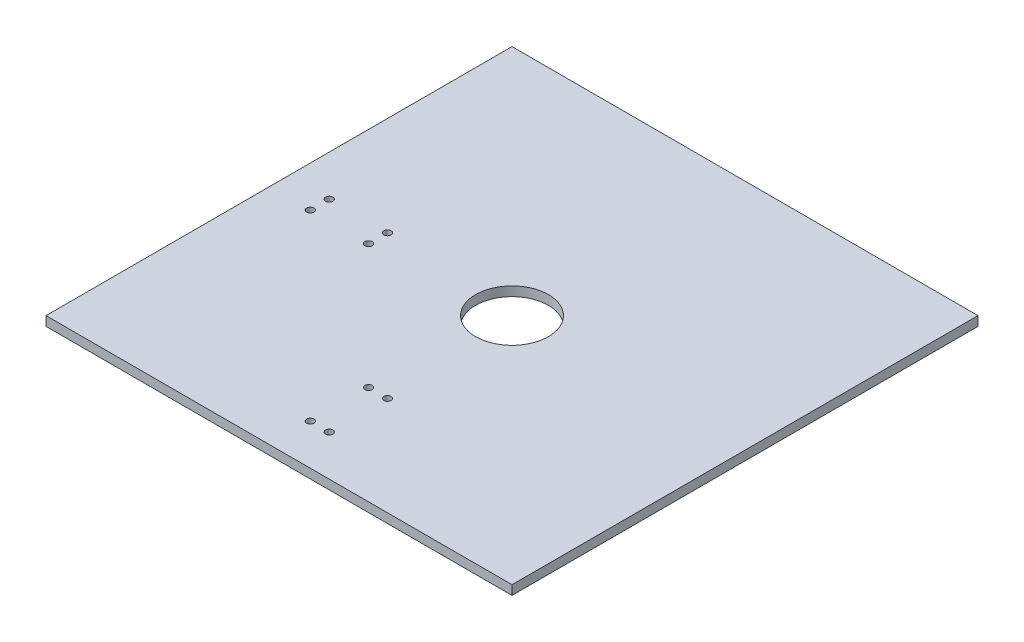
from build123d import *

# Parameters (mm, degrees)
SKETCH1_W                        = 203.2
SKETCH1_H                        = 203.2
BOSS_EXTRUDE1_DEPTH              = 4.064
F_1_8_0_125_DIAMETER_HOLE1_D     = 3.175
F_1_8_0_125_DIAMETER_HOLE1_DEPTH = 25.4
F_1_8_0_125_DIAMETER_HOLE1_TIP   = 0.953866233
F_5_8_0_625_DIAMETER_HOLE1_D     = 31.75
F_5_8_0_625_DIAMETER_HOLE1_DEPTH = 25.4
F_5_8_0_625_DIAMETER_HOLE1_TIP   = 9.538662327


with BuildPart() as part:
    # Sketch1 → Boss-Extrude1 (new body)
    with BuildSketch(Plane(origin=(0, 0, 0), x_dir=(1, 0, 0), z_dir=(0, 1, 0))):
        Rectangle(SKETCH1_W, SKETCH1_H)
    extrude(amount=BOSS_EXTRUDE1_DEPTH)

    # 1/8 (0.125) Diameter Hole1
    with Locations(Plane(origin=(0, 4.064, 0), x_dir=(1, 0, 0), z_dir=(0, 1, 0))):
        with Locations((-83.82, 4.1275), (-58.42, 4.1275), (-58.42, -4.1275), (-83.82, -4.1275), (-4.1275, -83.82), (-4.1275, -58.42), (4.1275, -58.42), (4.1275, -83.82)):
            Hole(F_1_8_0_125_DIAMETER_HOLE1_D / 2, depth=F_1_8_0_125_DIAMETER_HOLE1_DEPTH)
            with Locations((0, 0, -(F_1_8_0_125_DIAMETER_HOLE1_DEPTH + F_1_8_0_125_DIAMETER_HOLE1_TIP / 2))):  # 118° drill point
                Cone(0, F_1_8_0_125_DIAMETER_HOLE1_D / 2, F_1_8_0_125_DIAMETER_HOLE1_TIP, mode=Mode.SUBTRACT)

    # 5/8 (0.625) Diameter Hole1
    with Locations(Plane(origin=(0, 4.064, 0), x_dir=(1, 0, 0), z_dir=(0, 1, 0))):
        with Locations((0, 0)):
            Hole(F_5_8_0_625_DIAMETER_HOLE1_D / 2, depth=F_5_8_0_625_DIAMETER_HOLE1_DEPTH)
            with Locations((0, 0, -(F_5_8_0_625_DIAMETER_HOLE1_DEPTH + F_5_8_0_625_DIAMETER_HOLE1_TIP / 2))):  # 118° drill point
                Cone(0, F_5_8_0_625_DIAMETER_HOLE1_D / 2, F_5_8_0_625_DIAMETER_HOLE1_TIP, mode=Mode.SUBTRACT)


solid = part.part
